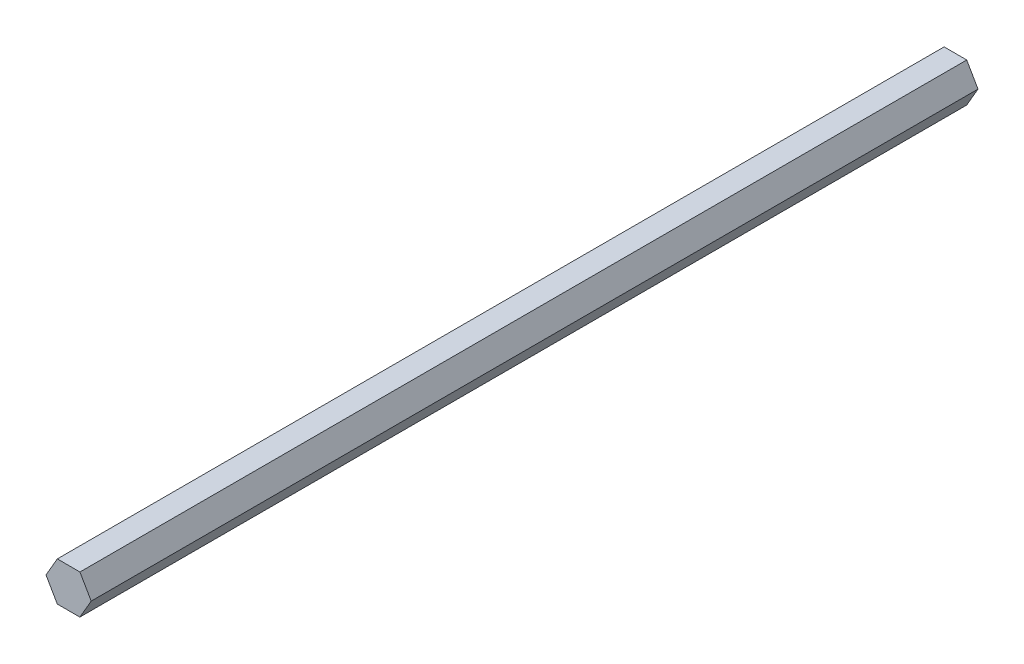
from build123d import *

# Parameters (mm, degrees)
BOSS_EXTRUDE1_DEPTH = 60.1599


with BuildPart() as part:
    # Sketch1 → Boss-Extrude1 (new body)
    with BuildSketch(Plane.XY):
        Polygon((0.769323595, 1.325855557), (-0.763562797, 1.329181555), (-1.532886392, 0.003325998), (-0.769323595, -1.325855557), (0.763562797, -1.329181555), (1.532886392, -0.003325998), align=None)
    extrude(amount=BOSS_EXTRUDE1_DEPTH)


solid = part.part
